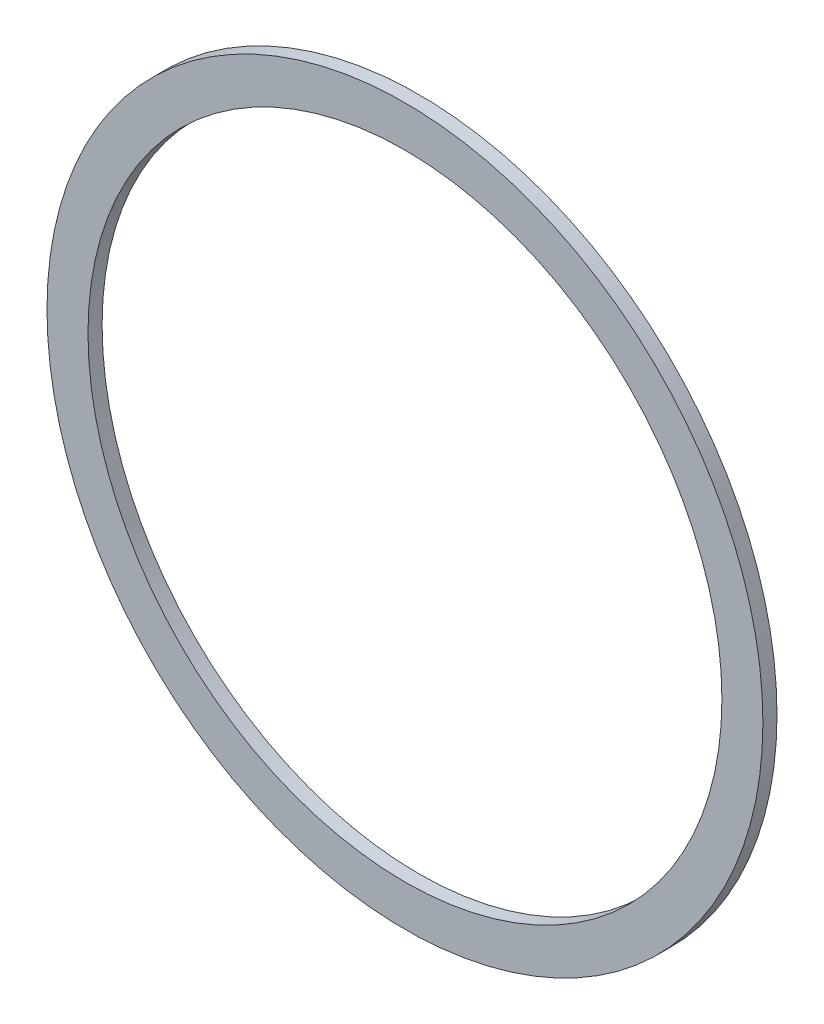
from build123d import *

# Parameters (mm, degrees)
SKETCH1_R           = 101.5
SKETCH1_R_2         = 89.875
BOSS_EXTRUDE1_DEPTH = 2


with BuildPart() as part:
    # Sketch1 → Boss-Extrude1 (new body, symmetric)
    with BuildSketch(Plane.XY):
        Circle(SKETCH1_R)
        Circle(SKETCH1_R_2, mode=Mode.SUBTRACT)
    extrude(amount=BOSS_EXTRUDE1_DEPTH, both=True)


solid = part.part
